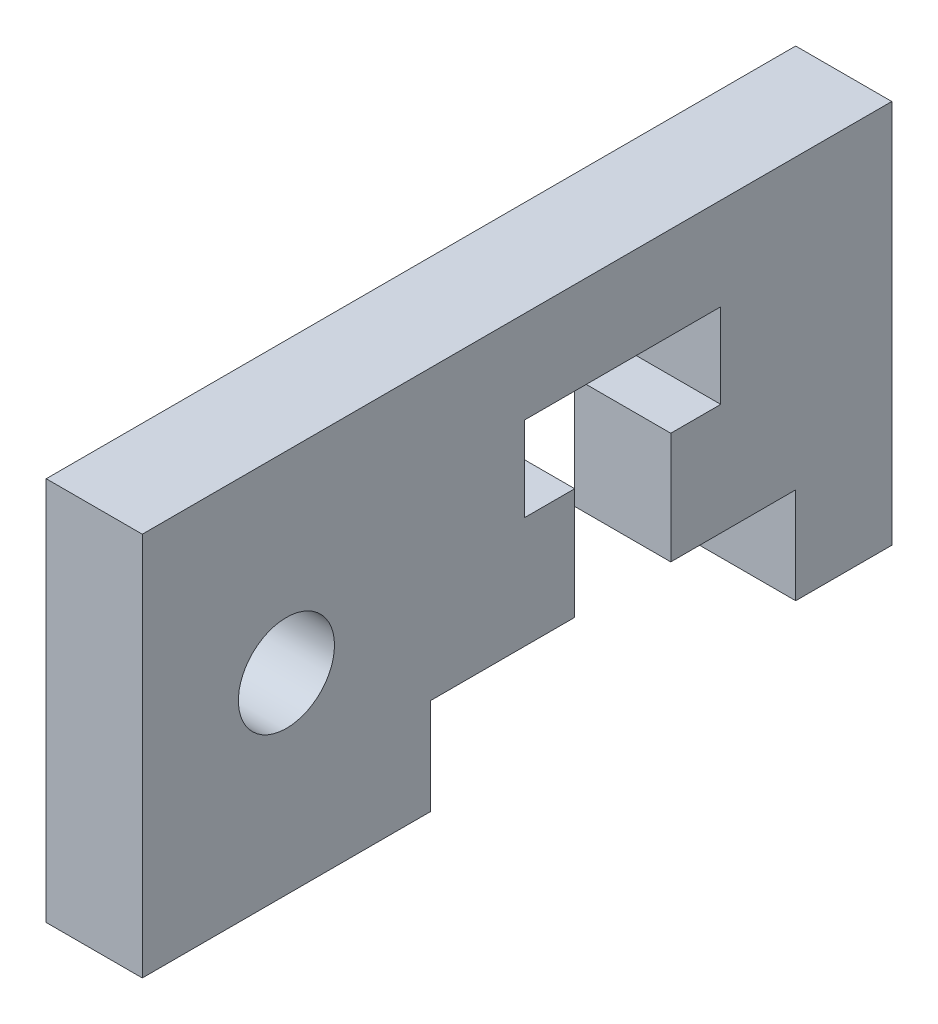
from build123d import *

# Parameters (mm, degrees)
BOSS_EXTRUDE1_DEPTH      = 1.5875
BOSS_EXTRUDE1_DEPTH_BACK = 1.5875
SKETCH2_R                = 1.5875


with BuildPart() as part:
    # Sketch2 → Boss-Extrude1 (new, two sides: drawn at the far end of the back side and taken through both)
    with BuildSketch(Plane(origin=(0, 0, 0), x_dir=(0, 0, -1), z_dir=(1, 0, 0)).offset(-BOSS_EXTRUDE1_DEPTH_BACK)):
        Polygon((-4.7625, 6.35), (-4.7625, -6.35), (4.7625, -6.35), (4.7625, -3.175), (9.525, -3.175), (9.525, 0.508), (7.874, 0.508), (7.874, 3.302), (14.351, 3.302), (14.351, 0.508), (12.7, 0.508), (12.7, -3.175), (16.8275, -3.175), (16.8275, -6.35), (20.0025, -6.35), (20.0025, 6.35), align=None)
        Circle(SKETCH2_R, mode=Mode.SUBTRACT)
    extrude(amount=BOSS_EXTRUDE1_DEPTH + BOSS_EXTRUDE1_DEPTH_BACK)


solid = part.part
